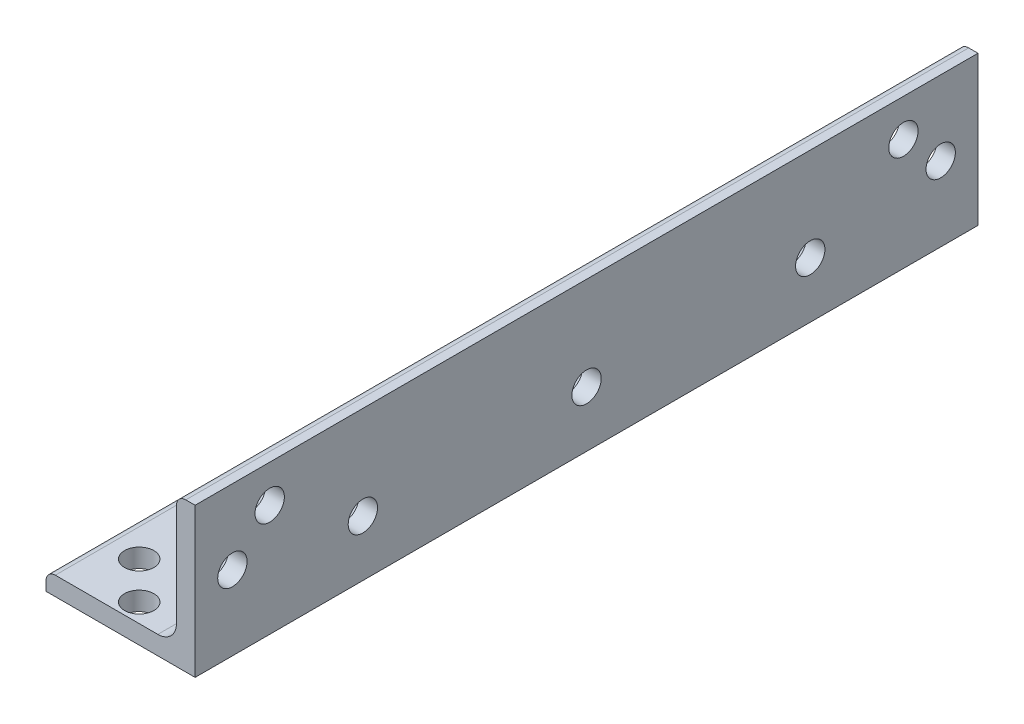
from build123d import *

# Parameters (mm, degrees)
BOSS_EXTRUDE1_DEPTH = 304.8
SKETCH7_W           = 25.4
SKETCH7_H           = 476.25
CUT_EXTRUDE1_DEPTH  = 254
SKETCH3_R           = 2.5
CUT_EXTRUDE2_DEPTH  = 254
SKETCH8_R           = 2.5
CUT_EXTRUDE4_DEPTH  = 254


with BuildPart() as part:
    # Sketch2 → Boss-Extrude1 (new, symmetric)
    with BuildSketch(Plane.XY):
        with BuildLine():
            Line((-12.7, -12.7), (12.7, -12.7))
            Line((12.7, -12.7), (12.7, 12.7))
            Line((12.7, 12.7), (11.1125, 12.7))
            ThreePointArc((11.1125, 12.7), (9.989967985, 12.235032015), (9.525, 11.1125))
            Line((9.525, 11.1125), (9.525, -6.35))
            ThreePointArc((9.525, -6.35), (8.59506403, -8.59506403), (6.35, -9.525))
            Line((6.35, -9.525), (-11.1125, -9.525))
            ThreePointArc((-11.1125, -9.525), (-12.235032015, -9.989967985), (-12.7, -11.1125))
            Line((-12.7, -11.1125), (-12.7, -12.7))
        make_face()
    extrude(amount=BOSS_EXTRUDE1_DEPTH, both=True)

    # Sketch7 → Cut-Extrude1 (cut)
    with BuildSketch(Plane.XZ.offset(12.7)):
        with Locations((0, 66.675)):
            Rectangle(SKETCH7_W, SKETCH7_H)
    extrude(amount=-CUT_EXTRUDE1_DEPTH, mode=Mode.SUBTRACT)

    # Sketch3 → Cut-Extrude2 (cut)
    with BuildSketch(Plane(origin=(0, 0, 0), x_dir=(1, 0, 0), z_dir=(0, 1, 0))):
        with Locations(Location((-6.35, 295.275, 0), (0, 0, 270))):
            Circle(SKETCH3_R)
        with Locations(Location((0, 301.625, 0), (0, 0, 270))):
            Circle(SKETCH3_R)
        with Locations(Location((3.175, 276.225, 0), (0, 0, 270))):
            Circle(SKETCH3_R)
        with Locations(Location((3.175, 238.125, 0), (0, 0, 270))):
            Circle(SKETCH3_R)
        with Locations(Location((3.175, 200.025, 0), (0, 0, 270))):
            Circle(SKETCH3_R)
        with Locations(Location((0, 174.625, 0), (0, 0, 270))):
            Circle(SKETCH3_R)
        with Locations(Location((-6.35, 180.975, 0), (0, 0, 270))):
            Circle(SKETCH3_R)
    extrude(amount=-CUT_EXTRUDE2_DEPTH, mode=Mode.SUBTRACT)

    # Sketch8 → Cut-Extrude4 (cut)
    with BuildSketch(Plane(origin=(12.7, 0, -12.7), x_dir=(0, 0, 1), z_dir=(-1, 0, 0))):
        with Locations(Location((-171.45, 6.35, 0), (0, 0, 90))):
            Circle(SKETCH8_R)
        with Locations(Location((-165.1, 0, 0), (0, 0, 90))):
            Circle(SKETCH8_R)
        with Locations(Location((-187.325, -3.175, 0), (0, 0, 90))):
            Circle(SKETCH8_R)
        with Locations(Location((-225.425, -3.175, 0), (0, 0, 90))):
            Circle(SKETCH8_R)
        with Locations(Location((-263.525, -3.175, 0), (0, 0, 90))):
            Circle(SKETCH8_R)
        with Locations(Location((-285.75, 0, 0), (0, 0, 90))):
            Circle(SKETCH8_R)
        with Locations(Location((-279.4, 6.35, 0), (0, 0, 90))):
            Circle(SKETCH8_R)
    extrude(amount=CUT_EXTRUDE4_DEPTH, mode=Mode.SUBTRACT)


solid = part.part
